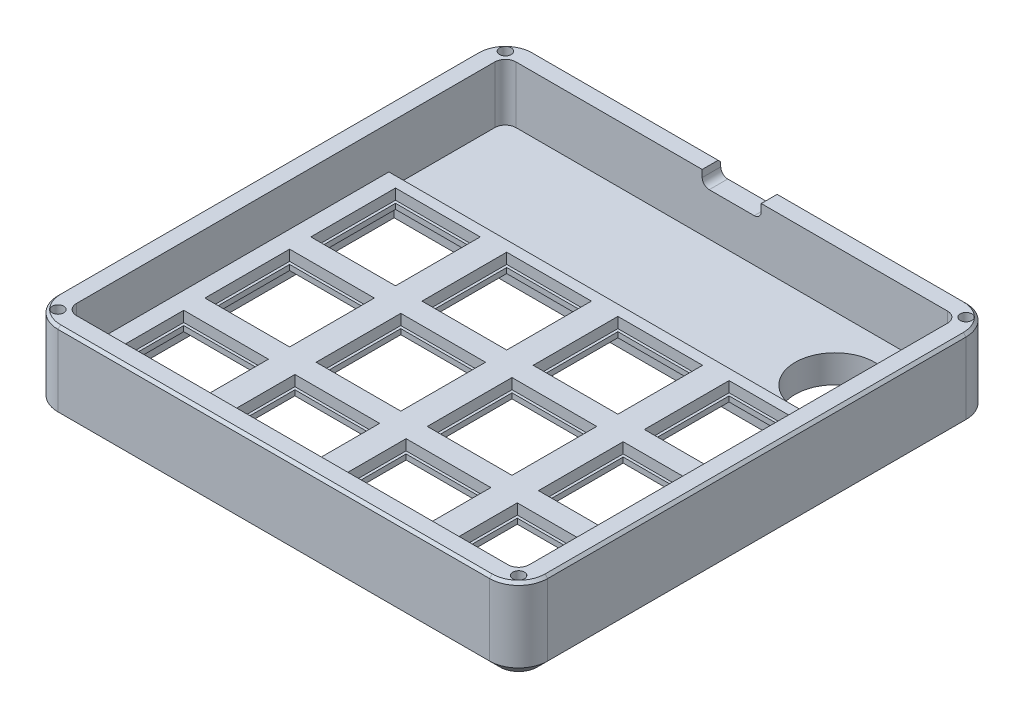
from build123d import *

# Parameters (mm, degrees)
BOSS_EXTRUDE1_DEPTH    = 16
CUT_EXTRUDE1_DEPTH     = 8
SKETCH4_W              = 16
SKETCH4_H              = 16
CUT_EXTRUDE2_DEPTH     = 9
SKETCH5_R              = 7.5
CUT_EXTRUDE3_DEPTH     = 17
CUT_EXTRUDE5_DEPTH     = 5
SKETCH9_R              = 1.1
CUT_EXTRUDE7_DEPTH     = 3
CUT_EXTRUDE6_DEPTH     = 2.75
CHAMFER1_SIZE          = 1
CHAMFER2_SIZE          = 2
CHAMFER3_SIZE          = 0.5
CUT_EXTRUDE8_DEPTH     = 3.5
SKETCH12_W             = 16
SKETCH12_H             = 16
SKETCH12_W_2           = 15
SKETCH12_H_2           = 15
BOSS_EXTRUDE2_DEPTH    = 1
BOSS_EXTRUDE2_2_DEPTH  = 1
BOSS_EXTRUDE2_3_DEPTH  = 1
BOSS_EXTRUDE2_4_DEPTH  = 1
BOSS_EXTRUDE2_5_DEPTH  = 1
BOSS_EXTRUDE2_6_DEPTH  = 1
BOSS_EXTRUDE2_7_DEPTH  = 1
BOSS_EXTRUDE2_8_DEPTH  = 1
BOSS_EXTRUDE2_9_DEPTH  = 1
BOSS_EXTRUDE2_10_DEPTH = 1
BOSS_EXTRUDE2_11_DEPTH = 1
BOSS_EXTRUDE2_12_DEPTH = 1


with BuildPart() as part:
    # Sketch1 → Boss-Extrude1 (new body)
    with BuildSketch(Plane(origin=(0, 0, 0), x_dir=(1, 0, 0), z_dir=(0, 1, 0))):
        with BuildLine():
            Line((-46.250726786, 39.5), (-46.250726786, -39.5))
            ThreePointArc((-46.250726786, -39.5), (-44.639601212, -43.389601212), (-40.75, -45.000726786))
            Line((-40.75, -45.000726786), (40.75, -45.000726786))
            ThreePointArc((40.75, -45.000726786), (44.639601212, -43.389601212), (46.250726786, -39.5))
            Line((46.250726786, -39.5), (46.250726786, 39.5))
            ThreePointArc((46.250726786, 39.5), (44.639601212, 43.389601212), (40.75, 45.000726786))
            Line((40.75, 45.000726786), (-40.75, 45.000726786))
            ThreePointArc((-40.75, 45.000726786), (-44.639601212, 43.389601212), (-46.250726786, 39.5))
        make_face()
    extrude(amount=BOSS_EXTRUDE1_DEPTH)

    # Sketch3 → Cut-Extrude1 (cut)
    with BuildSketch(Plane(origin=(0, 16, 0), x_dir=(1, 0, 0), z_dir=(0, 1, 0))):
        with BuildLine():
            Line((-42.750726786, 39.5), (-42.750726786, -39.5))
            ThreePointArc((-42.750726786, -39.5), (-42.164727477, -40.914727477), (-40.75, -41.500726786))
            Line((-40.75, -41.500726786), (40.75, -41.500726786))
            ThreePointArc((40.75, -41.500726786), (42.164727477, -40.914727477), (42.750726786, -39.5))
            Line((42.750726786, -39.5), (42.750726786, 39.5))
            ThreePointArc((42.750726786, 39.5), (42.164727477, 40.914727477), (40.75, 41.500726786))
            Line((40.75, 41.500726786), (-40.75, 41.500726786))
            ThreePointArc((-40.75, 41.500726786), (-42.164727477, 40.914727477), (-42.750726786, 39.5))
        make_face()
    extrude(amount=-CUT_EXTRUDE1_DEPTH, mode=Mode.SUBTRACT)

    # Sketch4 → Cut-Extrude2 (cut, through all)
    with BuildSketch(Plane(origin=(0, 8, 0), x_dir=(1, 0, 0), z_dir=(0, 1, 0))):
        with Locations((-10.500726786, 9.499273214)):
            Rectangle(SKETCH4_W, SKETCH4_H)
        with Locations((-31.500726786, 9.499273214)):
            Rectangle(SKETCH4_W, SKETCH4_H)
        with Locations((10.499273214, 9.499273214)):
            Rectangle(SKETCH4_W, SKETCH4_H)
        with Locations((31.499273214, 9.499273214)):
            Rectangle(SKETCH4_W, SKETCH4_H)
        with Locations((-31.500726786, -10.500726786)):
            Rectangle(SKETCH4_W, SKETCH4_H)
        with Locations((-10.500726786, -10.500726786)):
            Rectangle(SKETCH4_W, SKETCH4_H)
        with Locations((10.499273214, -10.500726786)):
            Rectangle(SKETCH4_W, SKETCH4_H)
        with Locations((31.499273214, -10.500726786)):
            Rectangle(SKETCH4_W, SKETCH4_H)
        with Locations((-31.500726786, -30.500726786)):
            Rectangle(SKETCH4_W, SKETCH4_H)
        with Locations((-10.500726786, -30.500726786)):
            Rectangle(SKETCH4_W, SKETCH4_H)
        with Locations((10.499273214, -30.500726786)):
            Rectangle(SKETCH4_W, SKETCH4_H)
        with Locations((31.499273214, -30.500726786)):
            Rectangle(SKETCH4_W, SKETCH4_H)
    extrude(amount=-CUT_EXTRUDE2_DEPTH, mode=Mode.SUBTRACT)

    # Sketch5 → Cut-Extrude3 (cut, through all)
    with BuildSketch(Plane(origin=(0, 16, 0), x_dir=(1, 0, 0), z_dir=(0, 1, 0))):
        with Locations((31.499273214, 29.5)):
            Circle(SKETCH5_R)
    extrude(amount=-CUT_EXTRUDE3_DEPTH, mode=Mode.SUBTRACT)

    # Sketch7 → Cut-Extrude5 (cut)
    with BuildSketch(Plane.XZ):
        with BuildLine():
            Line((-42.750726786, 39.5), (-42.750726786, -20.499273214))
            Line((-42.750726786, -20.499273214), (42.750726786, -20.499273214))
            Line((42.750726786, -20.499273214), (42.750726786, 39.5))
            ThreePointArc((42.750726786, 39.5), (42.164727477, 40.914727477), (40.75, 41.500726786))
            Line((40.75, 41.500726786), (-40.75, 41.500726786))
            ThreePointArc((-40.75, 41.500726786), (-42.164727477, 40.914727477), (-42.750726786, 39.5))
        make_face()
    extrude(amount=-CUT_EXTRUDE5_DEPTH, mode=Mode.SUBTRACT)

    # Sketch9 → Cut-Extrude7 (cut)
    with BuildSketch(Plane(origin=(0, 16, 0), x_dir=(1, 0, 0), z_dir=(0, 1, 0))):
        with Locations((-43.500363393, 42.250363393)):
            Circle(SKETCH9_R)
        with Locations((43.500363393, 42.250363393)):
            Circle(SKETCH9_R)
        with Locations((43.500363393, -42.250363393)):
            Circle(SKETCH9_R)
        with Locations((-43.500363393, -42.250363393)):
            Circle(SKETCH9_R)
    extrude(amount=-CUT_EXTRUDE7_DEPTH, mode=Mode.SUBTRACT)

    # Sketch6 → Cut-Extrude6 (cut)
    with BuildSketch(Plane.XZ.offset(-8)):
        with BuildLine():
            Line((-42.750726786, -20.499273214), (42.750726786, -20.499273214))
            Line((42.750726786, -20.499273214), (42.750726786, -39.5))
            ThreePointArc((42.750726786, -39.5), (42.164727477, -40.914727477), (40.75, -41.500726786))
            Line((40.75, -41.500726786), (-40.75, -41.500726786))
            ThreePointArc((-40.75, -41.500726786), (-42.164727477, -40.914727477), (-42.750726786, -39.5))
            Line((-42.750726786, -39.5), (-42.750726786, -20.499273214))
        make_face()
    extrude(amount=CUT_EXTRUDE6_DEPTH, mode=Mode.SUBTRACT)

    # Chamfer1
    chamfer1_edges = [part.edges().sort_by_distance(p)[0] for p in [
        (0, 8, -20.499273214),
    ]]
    chamfer(chamfer1_edges, length=CHAMFER1_SIZE)

    # Chamfer2
    chamfer2_edges = [part.edges().sort_by_distance(p)[0] for p in [
        (46.250726786, 0, 0),
        (44.639601212, 0, 43.389601212),
        (0, 0, 45.000726786),
        (-44.639601212, 0, 43.389601212),
        (-46.250726786, 0, 0),
        (-44.639601212, 0, -43.389601212),
        (0, 0, -45.000726786),
        (44.639601212, 0, -43.389601212),
    ]]
    chamfer(chamfer2_edges, length=CHAMFER2_SIZE)

    # Chamfer3
    chamfer3_edges = [part.edges().sort_by_distance(p)[0] for p in [
        (44.639601212, 16, 43.389601212),
        (46.250726786, 16, 0),
        (44.639601212, 16, -43.389601212),
        (0, 16, -45.000726786),
        (-44.639601212, 16, -43.389601212),
        (-46.250726786, 16, 0),
        (-44.639601212, 16, 43.389601212),
        (0, 16, 45.000726786),
    ]]
    chamfer(chamfer3_edges, length=CHAMFER3_SIZE)

    # Sketch11 → Cut-Extrude8 (cut)
    with BuildSketch(Plane(origin=(0, 0, -45.000726786), x_dir=(-1, 0, 0), z_dir=(0, 0, -1))):
        with BuildLine():
            Line((-4.25, 13.35), (4.25, 13.35))
            ThreePointArc((4.25, 13.35), (5.186916485, 13.738083515), (5.575, 14.675))
            Line((5.575, 14.675), (5.575, 16))
            Line((5.575, 16), (-5.575, 16))
            Line((-5.575, 16), (-5.575, 14.675))
            ThreePointArc((-5.575, 14.675), (-5.186916485, 13.738083515), (-4.25, 13.35))
        make_face()
    extrude(amount=-CUT_EXTRUDE8_DEPTH, mode=Mode.SUBTRACT)


with BuildPart() as body_2:
    # Sketch12 → Boss-Extrude2 (new body)
    with BuildSketch(Plane.XZ.offset(-5)):
        with Locations((-10.500726786, 30.500726786)):
            Rectangle(SKETCH12_W, SKETCH12_H)
        with Locations((-10.500726786, 30.500726786)):
            Rectangle(SKETCH12_W_2, SKETCH12_H_2, mode=Mode.SUBTRACT)
    extrude(amount=-BOSS_EXTRUDE2_DEPTH)


with BuildPart() as body_3:
    # Sketch12 → Boss-Extrude2 2 (new body)
    with BuildSketch(Plane.XZ.offset(-5)):
        with Locations((-31.500726786, 30.500726786)):
            Rectangle(SKETCH12_W, SKETCH12_H)
        with Locations((-31.500726786, 30.500726786)):
            Rectangle(SKETCH12_W_2, SKETCH12_H_2, mode=Mode.SUBTRACT)
    extrude(amount=-BOSS_EXTRUDE2_2_DEPTH)


with BuildPart() as body_4:
    # Sketch12 → Boss-Extrude2 3 (new body)
    with BuildSketch(Plane.XZ.offset(-5)):
        with Locations((10.499273214, 30.500726786)):
            Rectangle(SKETCH12_W, SKETCH12_H)
        with Locations((10.499273214, 30.500726786)):
            Rectangle(SKETCH12_W_2, SKETCH12_H_2, mode=Mode.SUBTRACT)
    extrude(amount=-BOSS_EXTRUDE2_3_DEPTH)


with BuildPart() as body_5:
    # Sketch12 → Boss-Extrude2 4 (new body)
    with BuildSketch(Plane.XZ.offset(-5)):
        with Locations((31.499273214, 30.500726786)):
            Rectangle(SKETCH12_W, SKETCH12_H)
        with Locations((31.499273214, 30.500726786)):
            Rectangle(SKETCH12_W_2, SKETCH12_H_2, mode=Mode.SUBTRACT)
    extrude(amount=-BOSS_EXTRUDE2_4_DEPTH)


with BuildPart() as body_6:
    # Sketch12 → Boss-Extrude2 5 (new body)
    with BuildSketch(Plane.XZ.offset(-5)):
        with Locations((-31.500726786, 10.500726786)):
            Rectangle(SKETCH12_W, SKETCH12_H)
        with Locations((-31.500726786, 10.500726786)):
            Rectangle(SKETCH12_W_2, SKETCH12_H_2, mode=Mode.SUBTRACT)
    extrude(amount=-BOSS_EXTRUDE2_5_DEPTH)


with BuildPart() as body_7:
    # Sketch12 → Boss-Extrude2 6 (new body)
    with BuildSketch(Plane.XZ.offset(-5)):
        with Locations((31.499273214, 10.500726786)):
            Rectangle(SKETCH12_W, SKETCH12_H)
        with Locations((31.499273214, 10.500726786)):
            Rectangle(SKETCH12_W_2, SKETCH12_H_2, mode=Mode.SUBTRACT)
    extrude(amount=-BOSS_EXTRUDE2_6_DEPTH)


with BuildPart() as body_8:
    # Sketch12 → Boss-Extrude2 7 (new body)
    with BuildSketch(Plane.XZ.offset(-5)):
        with Locations((10.499273214, 10.500726786)):
            Rectangle(SKETCH12_W, SKETCH12_H)
        with Locations((10.499273214, 10.500726786)):
            Rectangle(SKETCH12_W_2, SKETCH12_H_2, mode=Mode.SUBTRACT)
    extrude(amount=-BOSS_EXTRUDE2_7_DEPTH)


with BuildPart() as body_9:
    # Sketch12 → Boss-Extrude2 8 (new body)
    with BuildSketch(Plane.XZ.offset(-5)):
        with Locations((-10.500726786, 10.500726786)):
            Rectangle(SKETCH12_W, SKETCH12_H)
        with Locations((-10.500726786, 10.500726786)):
            Rectangle(SKETCH12_W_2, SKETCH12_H_2, mode=Mode.SUBTRACT)
    extrude(amount=-BOSS_EXTRUDE2_8_DEPTH)


with BuildPart() as body_10:
    # Sketch12 → Boss-Extrude2 9 (new body)
    with BuildSketch(Plane.XZ.offset(-5)):
        with Locations((-31.500726786, -9.499273214)):
            Rectangle(SKETCH12_W, SKETCH12_H)
        with Locations((-31.500726786, -9.499273214)):
            Rectangle(SKETCH12_W_2, SKETCH12_H_2, mode=Mode.SUBTRACT)
    extrude(amount=-BOSS_EXTRUDE2_9_DEPTH)


with BuildPart() as body_11:
    # Sketch12 → Boss-Extrude2 10 (new body)
    with BuildSketch(Plane.XZ.offset(-5)):
        with Locations((31.499273214, -9.499273214)):
            Rectangle(SKETCH12_W, SKETCH12_H)
        with Locations((31.499273214, -9.499273214)):
            Rectangle(SKETCH12_W_2, SKETCH12_H_2, mode=Mode.SUBTRACT)
    extrude(amount=-BOSS_EXTRUDE2_10_DEPTH)


with BuildPart() as body_12:
    # Sketch12 → Boss-Extrude2 11 (new body)
    with BuildSketch(Plane.XZ.offset(-5)):
        with Locations((10.499273214, -9.499273214)):
            Rectangle(SKETCH12_W, SKETCH12_H)
        with Locations((10.499273214, -9.499273214)):
            Rectangle(SKETCH12_W_2, SKETCH12_H_2, mode=Mode.SUBTRACT)
    extrude(amount=-BOSS_EXTRUDE2_11_DEPTH)


with BuildPart() as body_13:
    # Sketch12 → Boss-Extrude2 12 (new body)
    with BuildSketch(Plane.XZ.offset(-5)):
        with Locations((-10.500726786, -9.499273214)):
            Rectangle(SKETCH12_W, SKETCH12_H)
        with Locations((-10.500726786, -9.499273214)):
            Rectangle(SKETCH12_W_2, SKETCH12_H_2, mode=Mode.SUBTRACT)
    extrude(amount=-BOSS_EXTRUDE2_12_DEPTH)


solid = Compound([part.part, body_2.part, body_3.part, body_4.part, body_5.part, body_6.part, body_7.part, body_8.part, body_9.part, body_10.part, body_11.part, body_12.part, body_13.part])
